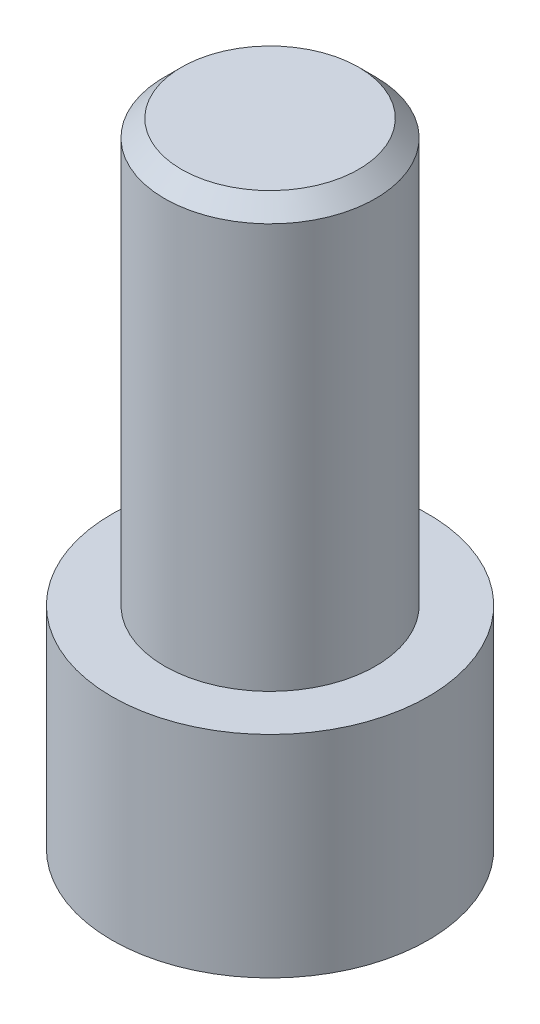
from build123d import *

# Parameters (mm, degrees)
CHAMFER1_SIZE      = 0.508
CUT_EXTRUDE1_DEPTH = 3.81


with BuildPart() as part:
    # Sketch1 → Revolve1 (revolve)
    with BuildSketch(Plane.XY):
        Polygon((0, 0), (0, 19.05), (3.175, 19.05), (3.175, 6.35), (4.7625, 6.35), (4.7625, 0), align=None)
    revolve(axis=Axis((0, 19.05, 0), (0, -1, 0)))

    # Chamfer1
    chamfer1_edges = [part.edges().sort_by_distance(p)[0] for p in [
        (-3.175, 19.05, 0),
    ]]
    chamfer(chamfer1_edges, length=CHAMFER1_SIZE)

    # Sketch2 → Cut-Extrude1 (cut)
    with BuildSketch(Plane.XZ):
        Polygon((1.721936672, -1.867226311), (2.478033756, 0.557627746), (0.756097084, 2.424854057), (-1.721936672, 1.867226311), (-2.478033756, -0.557627746), (-0.756097084, -2.424854057), align=None)
    extrude(amount=-CUT_EXTRUDE1_DEPTH, mode=Mode.SUBTRACT)


solid = part.part
